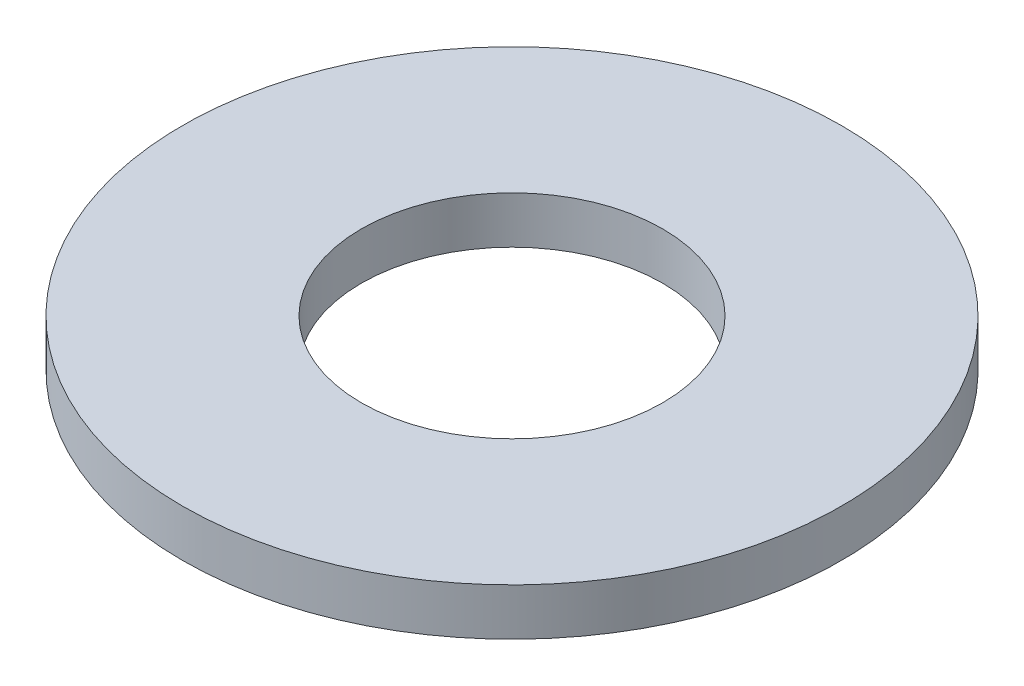
from build123d import *

# Parameters (mm, degrees)
ESQUISSE1_R        = 3.5
ESQUISSE1_R_2      = 1.6
BOSS_EXTRU_1_DEPTH = 0.5


with BuildPart() as part:
    # Esquisse1 → Boss.-Extru.1 (new body)
    with BuildSketch(Plane(origin=(0, 0, 0), x_dir=(1, 0, 0), z_dir=(0, 1, 0))):
        Circle(ESQUISSE1_R)
        Circle(ESQUISSE1_R_2, mode=Mode.SUBTRACT)
    extrude(amount=BOSS_EXTRU_1_DEPTH)


solid = part.part
